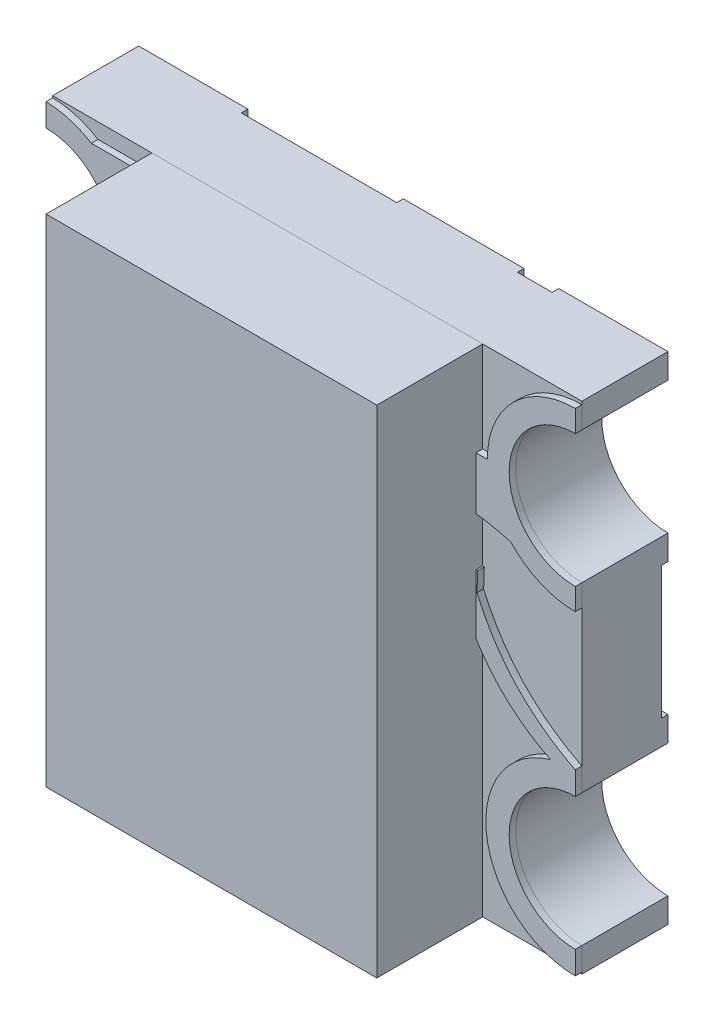
from build123d import *

# Parameters (mm, degrees)
BOSS_EXTRUDE1_DEPTH   = 0.24
SKETCH3_W             = 0.364889656
SKETCH3_H             = 1.5
BOSS_EXTRUDE2_DEPTH   = 0.02
BOSS_EXTRUDE3_DEPTH   = 0.02
BOSS_EXTRUDE3_2_DEPTH = 0.02
BOSS_EXTRUDE3_3_DEPTH = 0.02
BOSS_EXTRUDE3_4_DEPTH = 0.02
SKETCH5_W             = 0.648359628
SKETCH5_H             = 0.33862858
BOSS_EXTRUDE4_DEPTH   = 0.021
SKETCH5_W_2           = 0.173666543
SKETCH5_H_2           = 0.172266029
BOSS_EXTRUDE4_2_DEPTH = 0.021
SKETCH5_W_3           = 0.103954437
BOSS_EXTRUDE4_3_DEPTH = 0.021
SKETCH5_W_4           = 0.090039485
BOSS_EXTRUDE4_4_DEPTH = 0.021
SKETCH6_W             = 1
SKETCH6_H             = 1.5
BOSS_EXTRUDE5_DEPTH   = 0.32


with BuildPart() as part:
    # Sketch2 → Boss-Extrude1 (new body)
    with BuildSketch(Plane(origin=(0, 0, 0.02), x_dir=(-1, 0, 0), z_dir=(0, 0, -1))):
        with BuildLine():
            Line((0.8, -0.75), (-0.8, -0.75))
            Line((-0.8, -0.75), (-0.8, -0.675))
            ThreePointArc((-0.8, -0.675), (-0.6, -0.475), (-0.8, -0.275))
            Line((-0.8, -0.275), (-0.8, 0.275))
            ThreePointArc((-0.8, 0.275), (-0.6, 0.475), (-0.8, 0.675))
            Line((-0.8, 0.675), (-0.8, 0.75))
            Line((-0.8, 0.75), (0.8, 0.75))
            Line((0.8, 0.75), (0.8, 0.675))
            ThreePointArc((0.8, 0.675), (0.6, 0.475), (0.8, 0.275))
            Line((0.8, 0.275), (0.8, -0.275))
            ThreePointArc((0.8, -0.275), (0.6, -0.475), (0.8, -0.675))
            Line((0.8, -0.675), (0.8, -0.75))
        make_face()
    extrude(amount=-BOSS_EXTRUDE1_DEPTH)

    # Sketch3 → Boss-Extrude2 (add)
    with BuildSketch(Plane(origin=(0, 0, 0.02), x_dir=(-1, 0, 0), z_dir=(0, 0, -1))):
        with BuildLine():
            ThreePointArc((-0.8, 0.675), (-0.6, 0.475), (-0.8, 0.275))
            Line((-0.8, 0.275), (-0.8, 0.2))
            Line((-0.8, 0.2), (-0.47, 0.2))
            Line((-0.47, 0.2), (-0.47, 0.75))
            Line((-0.47, 0.75), (-0.8, 0.75))
            Line((-0.8, 0.75), (-0.8, 0.675))
        make_face()
        with BuildLine():
            Line((0.8, 0.75), (0.47, 0.75))
            Line((0.47, 0.75), (0.47, 0.2))
            Line((0.47, 0.2), (0.8, 0.2))
            Line((0.8, 0.2), (0.8, 0.275))
            ThreePointArc((0.8, 0.275), (0.6, 0.475), (0.8, 0.675))
            Line((0.8, 0.675), (0.8, 0.75))
        make_face()
        with BuildLine():
            Line((0.47, -0.2), (0.47, -0.75))
            Line((0.47, -0.75), (0.8, -0.75))
            Line((0.8, -0.75), (0.8, -0.675))
            ThreePointArc((0.8, -0.675), (0.6, -0.475), (0.8, -0.275))
            Line((0.8, -0.275), (0.8, -0.2))
            Line((0.8, -0.2), (0.47, -0.2))
        make_face()
        with BuildLine():
            Line((-0.47, -0.2), (-0.8, -0.2))
            Line((-0.8, -0.2), (-0.8, -0.275))
            ThreePointArc((-0.8, -0.275), (-0.6, -0.475), (-0.8, -0.675))
            Line((-0.8, -0.675), (-0.8, -0.75))
            Line((-0.8, -0.75), (-0.47, -0.75))
            Line((-0.47, -0.75), (-0.47, -0.2))
        make_face()
        with Locations((-0.182444828, 0)):
            Rectangle(SKETCH3_W, SKETCH3_H)
    extrude(amount=BOSS_EXTRUDE2_DEPTH)


with BuildPart() as body_2:
    # Sketch4 → Boss-Extrude3 (new body)
    with BuildSketch(Plane.XY.offset(0.26)):
        with BuildLine():
            Line((-0.55262711, 0.568724782), (0.267931494, 0.568724782))
            Line((0.267931494, 0.568724782), (0.267931494, 0.703885858))
            Line((0.267931494, 0.703885858), (-0.663199393, 0.703885858))
            ThreePointArc((-0.663199393, 0.703885858), (-0.728878813, 0.733289444), (-0.8, 0.744250009))
            Line((-0.8, 0.744250009), (-0.8, 0.675))
            ThreePointArc((-0.8, 0.675), (-0.6, 0.475), (-0.8, 0.275))
            Line((-0.8, 0.275), (-0.8, 0.205749991))
            ThreePointArc((-0.8, 0.205749991), (-0.582556434, 0.32334047), (-0.55262711, 0.568724782))
        make_face()
    extrude(amount=BOSS_EXTRUDE3_DEPTH)


with BuildPart() as body_3:
    # Sketch4 → Boss-Extrude3 2 (new body)
    with BuildSketch(Plane.XY.offset(0.26)):
        with BuildLine():
            ThreePointArc((-0.536123517, -0.518574745), (-0.59605929, -0.301974732), (-0.8, -0.207549899))
            Line((-0.8, -0.207549899), (-0.8, -0.275))
            ThreePointArc((-0.8, -0.275), (-0.6, -0.475), (-0.8, -0.675))
            Line((-0.8, -0.675), (-0.8, -0.742450101))
            ThreePointArc((-0.8, -0.742450101), (-0.651106302, -0.697171607), (-0.55262711, -0.576667151))
            add(Edge.make_bspline(
                [(-0.46486985, -0.549964588), (-0.51353684, -0.541816399), (-0.55262711, -0.576667151)],
                knots=[0, 0, 0, 1, 1, 1], degree=2))
            Line((-0.46486985, -0.549964588), (0.357478318, -0.564091672))
            Line((0.357478318, -0.564091672), (0.365094176, -0.120766819))
            Line((0.365094176, -0.120766819), (-0.46486985, -0.106508902))
            Line((-0.46486985, -0.106508902), (-0.47102587, -0.464855466))
            add(Edge.make_bspline(
                [(-0.47102587, -0.464855466), (-0.508313543, -0.485676411), (-0.536123517, -0.518574745)],
                knots=[0, 0, 0, 1, 1, 1], degree=2))
        make_face()
    extrude(amount=BOSS_EXTRUDE3_2_DEPTH)


with BuildPart() as body_4:
    # Sketch4 → Boss-Extrude3 3 (new body)
    with BuildSketch(Plane.XY.offset(0.26)):
        with BuildLine():
            Line((0.8, 0.675), (0.8, 0.741040809))
            ThreePointArc((0.8, 0.741040809), (0.61188074, 0.66311926), (0.533959191, 0.475))
            Line((0.533959191, 0.475), (-0.46486985, 0.475))
            Line((-0.46486985, 0.475), (-0.46486985, 0.013494022))
            Line((-0.46486985, 0.013494022), (0.267931494, 0.013494022))
            Line((0.267931494, 0.013494022), (0.267931494, 0.318843267))
            add(Edge.make_bspline(
                [(0.267931494, 0.318843267), (0.436380332, 0.339941299), (0.605022941, 0.293998181)],
                knots=[0, 0, 0, 1, 1, 1], degree=2))
            ThreePointArc((0.605022941, 0.293998181), (0.693642486, 0.231143913), (0.8, 0.208959191))
            Line((0.8, 0.208959191), (0.8, 0.275))
            ThreePointArc((0.8, 0.275), (0.6, 0.475), (0.8, 0.675))
        make_face()
    extrude(amount=BOSS_EXTRUDE3_3_DEPTH)


with BuildPart() as body_5:
    # Sketch4 → Boss-Extrude3 4 (new body)
    with BuildSketch(Plane.XY.offset(0.26)):
        with BuildLine():
            ThreePointArc((0.724836424, -0.215726527), (0.53219209, -0.51294441), (0.8, -0.74474008))
            Line((0.8, -0.74474008), (0.8, -0.675))
            ThreePointArc((0.8, -0.675), (0.6, -0.475), (0.8, -0.275))
            Line((0.8, -0.275), (0.8, -0.20525992))
            add(Edge.make_bspline(
                [(0.502812267, 0.110047945), (0.594372412, -0.101596658), (0.8, -0.20525992)],
                knots=[0, 0, 0, 1, 1, 1], degree=2))
            Line((0.502812267, 0.110047945), (0.504839123, 0.16853681))
            Line((0.504839123, 0.16853681), (0.381245584, 0.172819783))
            Line((0.381245584, 0.172819783), (0.375256739, 0))
            Line((0.375256739, 0), (0.495206718, -0.00415671))
            add(Edge.make_bspline(
                [(0.495206718, -0.00415671), (0.577565826, -0.142488492), (0.724836424, -0.215726527)],
                knots=[0, 0, 0, 1, 1, 1], degree=2))
        make_face()
    extrude(amount=BOSS_EXTRUDE3_4_DEPTH)


with BuildPart() as body_6:
    # Sketch5 → Boss-Extrude4 (new body)
    with BuildSketch(Plane.XY.offset(0.26)):
        with Locations((-0.110133942, 0.224509115)):
            Rectangle(SKETCH5_W, SKETCH5_H)
    extrude(amount=BOSS_EXTRUDE4_DEPTH)


with BuildPart() as body_7:
    # Sketch5 → Boss-Extrude4 2 (new body)
    with BuildSketch(Plane.XY.offset(0.26)):
        with Locations((-0.030990211, -0.445513551)):
            Rectangle(SKETCH5_W_2, SKETCH5_H_2)
    extrude(amount=BOSS_EXTRUDE4_2_DEPTH)


with BuildPart() as body_8:
    # Sketch5 → Boss-Extrude4 3 (new body)
    with BuildSketch(Plane.XY.offset(0.26)):
        with Locations((-0.361571177, -0.445513551)):
            Rectangle(SKETCH5_W_3, SKETCH5_H_2)
    extrude(amount=BOSS_EXTRUDE4_3_DEPTH)


with BuildPart() as body_9:
    # Sketch5 → Boss-Extrude4 4 (new body)
    with BuildSketch(Plane.XY.offset(0.26)):
        with Locations((0.298247329, -0.445513551)):
            Rectangle(SKETCH5_W_4, SKETCH5_H_2)
    extrude(amount=BOSS_EXTRUDE4_4_DEPTH)


with BuildPart() as body_10:
    # Sketch6 → Boss-Extrude5 (new body)
    with BuildSketch(Plane.XY.offset(0.26)):
        Rectangle(SKETCH6_W, SKETCH6_H)
    extrude(amount=BOSS_EXTRUDE5_DEPTH)


solid = Compound([part.part, body_2.part, body_3.part, body_4.part, body_5.part, body_6.part, body_7.part, body_8.part, body_9.part, body_10.part])
